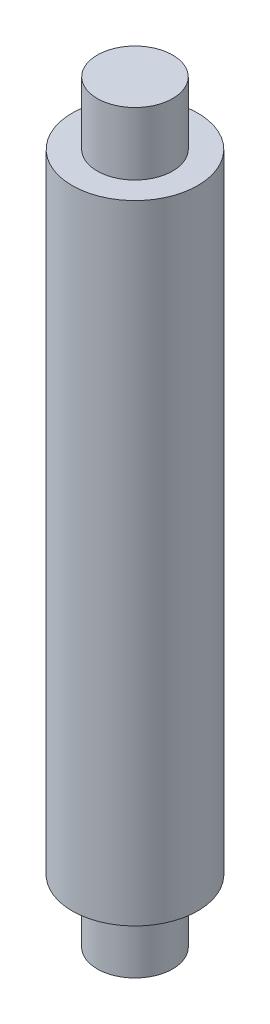
from build123d import *


with BuildPart() as part:
    # Croquis1 → Revolución1 (revolve)
    with BuildSketch(Plane(origin=(0, 0, 0), x_dir=(0, 0, -1), z_dir=(1, 0, 0))):
        Polygon((0, 60), (0, -60), (-6, -60), (-6, -50), (-10, -50), (-10, 50), (-6, 50), (-6, 60), align=None)
    revolve(axis=Axis((0, 60, 0), (0, -1, 0)))


solid = part.part
